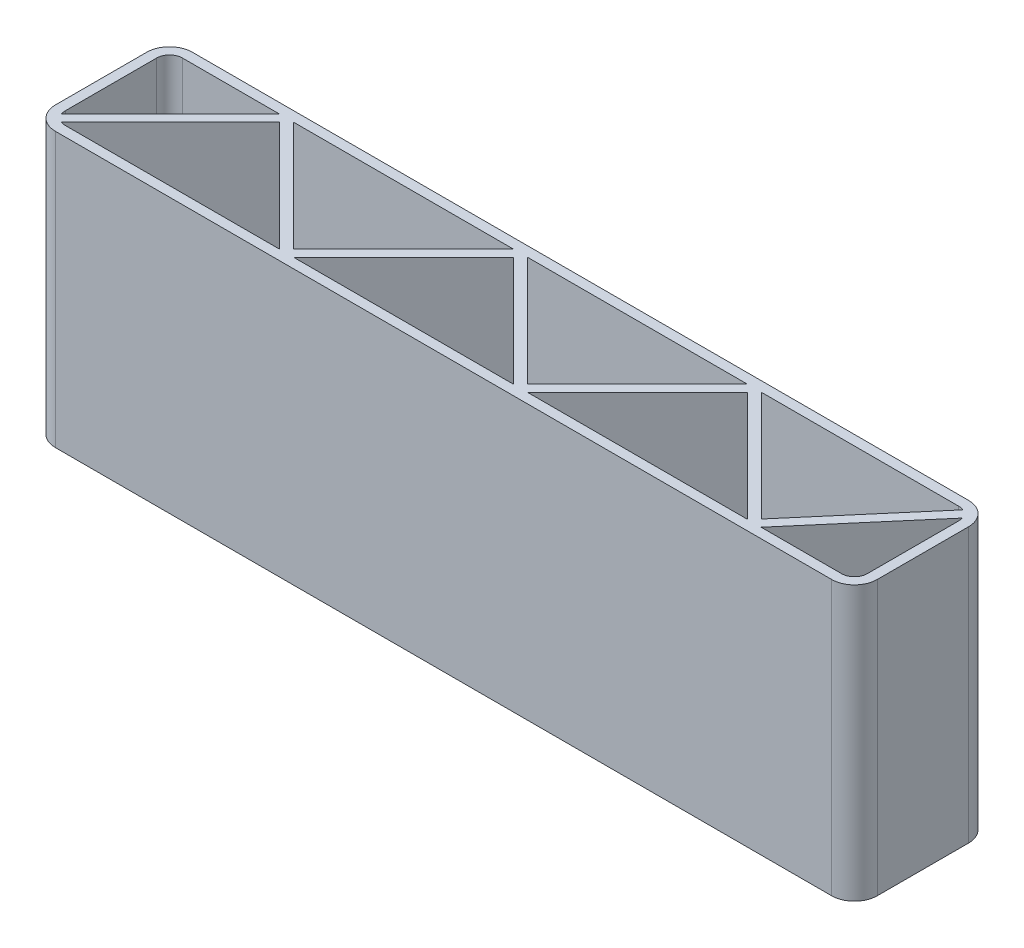
from build123d import *

# Parameters (mm, degrees)
EXTRUDE_THIN1_DEPTH = 609.6
EXTRUDE_THIN3_DEPTH = 609.6


with BuildPart() as part:
    # Sketch1 → Extrude-Thin1 (new body)
    with BuildSketch(Plane(origin=(0, 0, 0), x_dir=(1, 0, 0), z_dir=(0, 1, 0))):
        with BuildLine():
            Line((-863.6, 152.4), (863.6, 152.4))
            ThreePointArc((863.6, 152.4), (899.521024484, 137.521024484), (914.4, 101.6))
            Line((914.4, 101.6), (914.4, -101.6))
            ThreePointArc((914.4, -101.6), (899.521024484, -137.521024484), (863.6, -152.4))
            Line((863.6, -152.4), (-863.6, -152.4))
            ThreePointArc((-863.6, -152.4), (-899.521024484, -137.521024484), (-914.4, -101.6))
            Line((-914.4, -101.6), (-914.4, 101.6))
            ThreePointArc((-914.4, 101.6), (-899.521024484, 137.521024484), (-863.6, 152.4))
        make_face()
        with BuildLine():
            Line((-863.6, 130.175), (863.6, 130.175))
            ThreePointArc((863.6, 130.175), (883.805576272, 121.805576272), (892.175, 101.6))
            Line((892.175, 101.6), (892.175, -101.6))
            ThreePointArc((892.175, -101.6), (883.805576272, -121.805576272), (863.6, -130.175))
            Line((863.6, -130.175), (-863.6, -130.175))
            ThreePointArc((-863.6, -130.175), (-883.805576272, -121.805576272), (-892.175, -101.6))
            Line((-892.175, -101.6), (-892.175, 101.6))
            ThreePointArc((-892.175, 101.6), (-883.805576272, 121.805576272), (-863.6, 130.175))
        make_face(mode=Mode.SUBTRACT)
    extrude(amount=EXTRUDE_THIN1_DEPTH)

    # Sketch2 → Extrude-Thin3 (add)
    with BuildSketch(Plane(origin=(0, 609.6, 0), x_dir=(1, 0, 0), z_dir=(0, 1, 0))):
        Polygon((-884.317275894, -138.032724106), (-631.825, 114.459551788), (-371.475, -145.890448212), (-111.125, 114.459551788), (149.225, -145.890448212), (409.575, 114.459551788), (670.56979597, -146.535244182), (900.626773031, 122.960071803), (883.723226969, 137.389928197), (669.28020403, -113.814755818), (409.575, 145.890448212), (149.225, -114.459551788), (-111.125, 145.890448212), (-371.475, -114.459551788), (-631.825, 145.890448212), (-900.032724106, -122.317275894), align=None)
    extrude(amount=-EXTRUDE_THIN3_DEPTH)


solid = part.part
